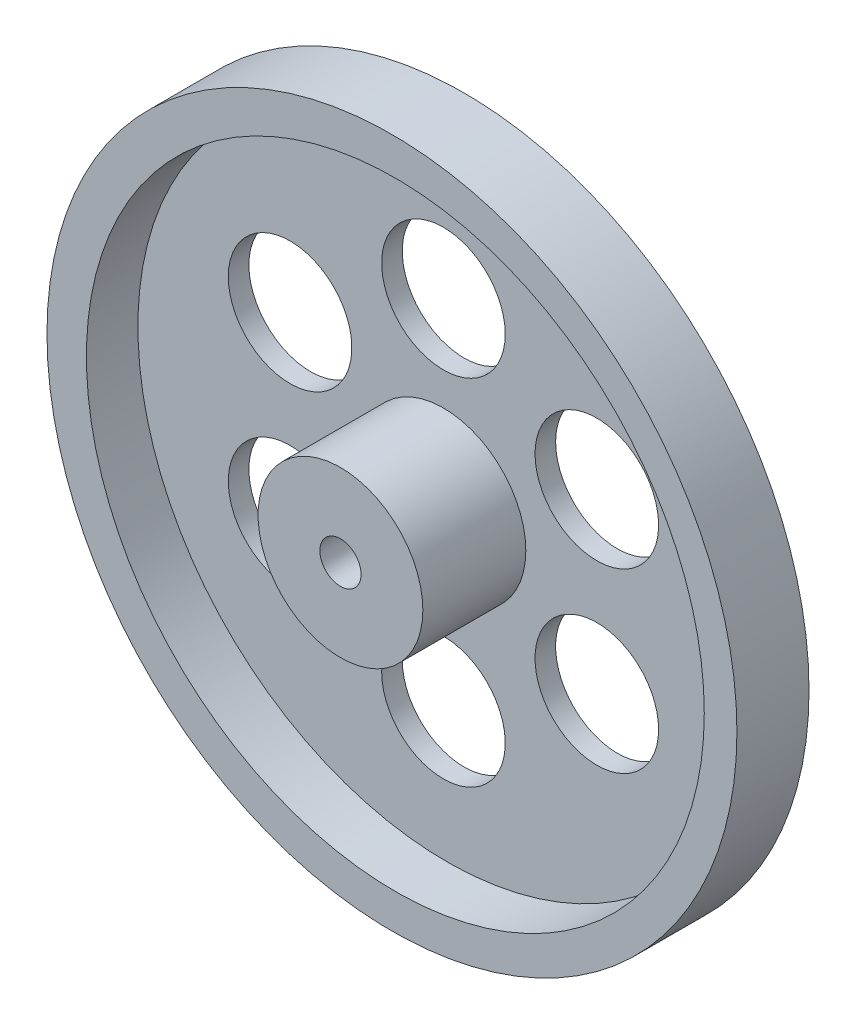
from build123d import *

# Parameters (mm, degrees)
SKETCH1_R           = 33.5
BOSS_EXTRUDE1_DEPTH = 7
SKETCH2_R           = 30
CUT_EXTRUDE1_DEPTH  = 5
SKETCH3_R           = 8
BOSS_EXTRUDE2_DEPTH = 10
SKETCH4_R           = 2
CUT_EXTRUDE2_DEPTH  = 30
SKETCH5_R           = 6
CUT_EXTRUDE3_DEPTH  = 3
CIRPATTERN1_COUNT   = 6


with BuildPart() as part:
    # Sketch1 → Boss-Extrude1 (new body)
    with BuildSketch(Plane.XY):
        Circle(SKETCH1_R)
    extrude(amount=BOSS_EXTRUDE1_DEPTH)

    # Sketch2 → Cut-Extrude1 (cut)
    with BuildSketch(Plane.XY.offset(7)):
        with Locations((0.329125808, 0)):
            Circle(SKETCH2_R)
    extrude(amount=-CUT_EXTRUDE1_DEPTH, mode=Mode.SUBTRACT)

    # Sketch3 → Boss-Extrude2 (add)
    with BuildSketch(Plane.XY.offset(2)):
        Circle(SKETCH3_R)
    extrude(amount=BOSS_EXTRUDE2_DEPTH)

    # Sketch4 → Cut-Extrude2 (cut)
    with BuildSketch(Plane.XY.offset(12)):
        Circle(SKETCH4_R)
    extrude(amount=-CUT_EXTRUDE2_DEPTH, mode=Mode.SUBTRACT)

    # Sketch5 → Cut-Extrude3 (cut, through all)
    with BuildSketch(Plane.XY.offset(2)):
        with Locations((0, 17.196823471)):
            Circle(SKETCH5_R)
    cut_extrude3 = extrude(amount=-CUT_EXTRUDE3_DEPTH, mode=Mode.SUBTRACT)

    # CirPattern1: Cut-Extrude3 ×6 about axis
    cirpattern1_axis = Axis((0, 0, 0), (0, 0, 1))
    for i in range(1, CIRPATTERN1_COUNT):
        add(cut_extrude3.rotate(cirpattern1_axis, i * 360 / CIRPATTERN1_COUNT), mode=Mode.SUBTRACT)


solid = part.part
